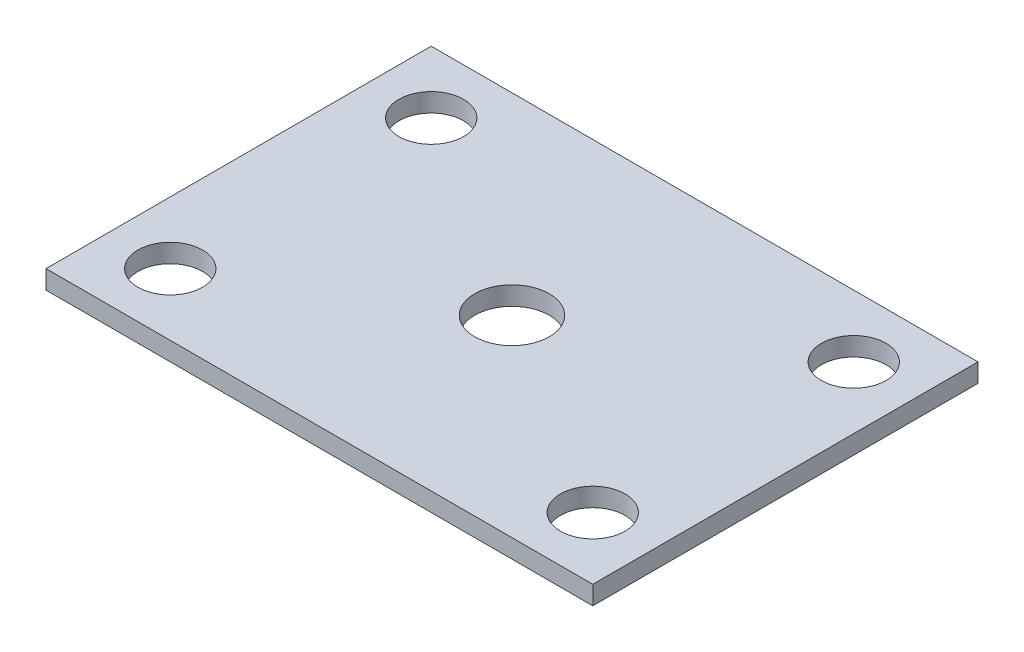
from build123d import *

# Parameters (mm, degrees)
SKETCH1_W           = 44
SKETCH1_H           = 31
BOSS_EXTRUDE1_DEPTH = 1.5
SKETCH2_R           = 2.6
SKETCH2_R_2         = 3
CUT_EXTRUDE1_DEPTH  = 1.5


with BuildPart() as part:
    # Sketch1 → Boss-Extrude1 (new body)
    with BuildSketch(Plane(origin=(0, 0, 0), x_dir=(1, 0, 0), z_dir=(0, 1, 0))):
        Rectangle(SKETCH1_W, SKETCH1_H)
    extrude(amount=BOSS_EXTRUDE1_DEPTH)

    # Sketch2 → Cut-Extrude1 (cut)
    with BuildSketch(Plane(origin=(0, 1.5, 0), x_dir=(1, 0, 0), z_dir=(0, 1, 0))):
        with Locations((-17, 10.5)):
            Circle(SKETCH2_R)
        with Locations((17, 10.5)):
            Circle(SKETCH2_R)
        with Locations((17, -10.5)):
            Circle(SKETCH2_R)
        with Locations((-17, -10.5)):
            Circle(SKETCH2_R)
        Circle(SKETCH2_R_2)
    extrude(amount=-CUT_EXTRUDE1_DEPTH, mode=Mode.SUBTRACT)


solid = part.part
